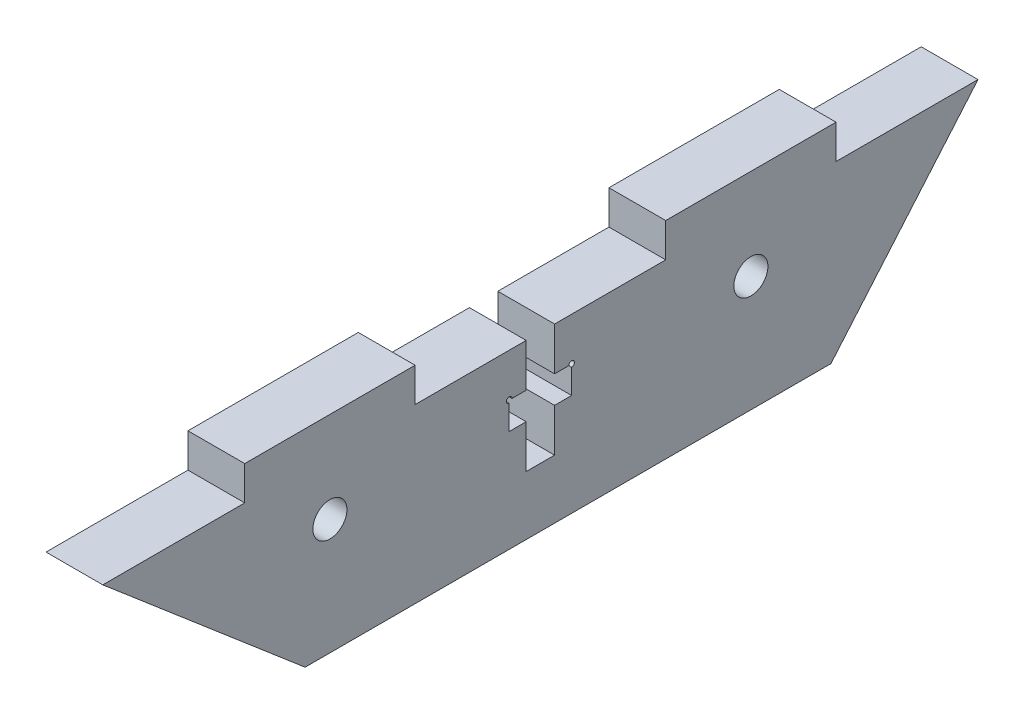
from build123d import *

# Parameters (mm, degrees)
SCHIZZO1_W                   = 77.07
SCHIZZO1_H                   = 15.19
ESTRUSIONE_ESTRUSIONE1_DEPTH = 5
TAGLIO_ESTRUSIONE1_DEPTH     = 6
SCHIZZO3_R                   = 1.5
TAGLIO_ESTRUSIONE2_DEPTH     = 6
SCHIZZO4_W                   = 5
SCHIZZO4_H                   = 15
ESTRUSIONE_ESTRUSIONE2_DEPTH = 3
TAGLIO_ESTRUSIONE3_DEPTH     = 6
SCHIZZO7_R                   = 0.25
TAGLIO_ESTRUSIONE4_DEPTH     = 10


with BuildPart() as part:
    # Schizzo1 → Estrusione-Estrusione1 (new body)
    with BuildSketch(Plane(origin=(0, 0, 0), x_dir=(0, 0, -1), z_dir=(1, 0, 0))):
        Rectangle(SCHIZZO1_W, SCHIZZO1_H)
    extrude(amount=ESTRUSIONE_ESTRUSIONE1_DEPTH)

    # Schizzo2 → Taglio-Estrusione1 (cut, through all)
    with BuildSketch(Plane(origin=(0, 0, 0), x_dir=(0, 0, -1), z_dir=(1, 0, 0))):
        Polygon((38.535, 7.595), (25.584422571, -7.595), (38.535, -7.595), align=None)
        Polygon((-38.535, 7.595), (-38.535, -7.595), (-20.718334969, -7.595), align=None)
    extrude(amount=TAGLIO_ESTRUSIONE1_DEPTH, mode=Mode.SUBTRACT)

    # Schizzo3 → Taglio-Estrusione2 (cut, through all)
    with BuildSketch(Plane(origin=(0, 0, 0), x_dir=(0, 0, -1), z_dir=(1, 0, 0))):
        with Locations((-18.535, 2.595)):
            Circle(SCHIZZO3_R)
        with Locations((18.535, 2.595)):
            Circle(SCHIZZO3_R)
    extrude(amount=TAGLIO_ESTRUSIONE2_DEPTH, mode=Mode.SUBTRACT)

    # Schizzo4 → Estrusione-Estrusione2 (add)
    with BuildSketch(Plane(origin=(0, 7.595, 0), x_dir=(1, 0, 0), z_dir=(0, 1, 0))):
        with Locations((2.5, 18.535)):
            Rectangle(SCHIZZO4_W, SCHIZZO4_H)
        with Locations((2.5, -18.535)):
            Rectangle(SCHIZZO4_W, SCHIZZO4_H)
    extrude(amount=ESTRUSIONE_ESTRUSIONE2_DEPTH)

    # Schizzo6 → Taglio-Estrusione3 (cut, through all)
    with BuildSketch(Plane(origin=(0, 0, 0), x_dir=(0, 0, -1), z_dir=(1, 0, 0))):
        Polygon((-1.25, -2.405), (-1.25, 1.395), (-2.75, 1.395), (-2.75, 3.795), (-1.25, 3.795), (-1.25, 7.595), (1.25, 7.595), (1.25, 3.795), (2.75, 3.795), (2.75, 1.395), (1.25, 1.395), (1.25, -2.405), align=None)
    extrude(amount=TAGLIO_ESTRUSIONE3_DEPTH, mode=Mode.SUBTRACT)

    # Schizzo7 → Taglio-Estrusione4 (cut)
    with BuildSketch(Plane(origin=(5, 0, 0), x_dir=(0, 0, -1), z_dir=(1, 0, 0))):
        with Locations((-2.75, 3.795)):
            Circle(SCHIZZO7_R)
        with Locations((2.75, 3.795)):
            Circle(SCHIZZO7_R)
    extrude(amount=-TAGLIO_ESTRUSIONE4_DEPTH, mode=Mode.SUBTRACT)


solid = part.part
